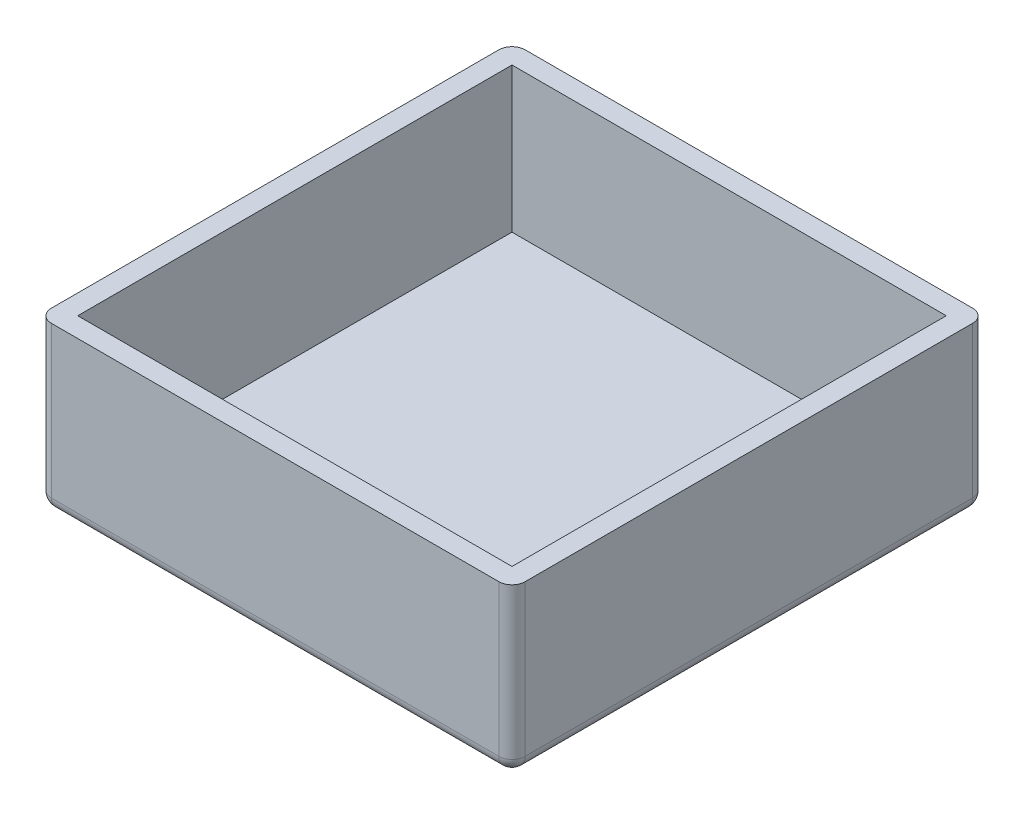
from build123d import *

# Parameters (mm, degrees)
SKETCH_1_W        = 66
SKETCH_1_H        = 66
EXTRUDE_1_DEPTH   = 3
SKETCH_1_2_W      = 72
SKETCH_1_2_H      = 72
SKETCH_1_2_W_2    = 66
SKETCH_1_2_H_2    = 66
EXTRUDE_1_2_DEPTH = 25
FILLET_1_R        = 2


with BuildPart() as part:
    # 草图1 → Extrude 1 (new body)
    with BuildSketch(Plane(origin=(0, 0, 0), x_dir=(1, 0, 0), z_dir=(0, 1, 0))):
        Rectangle(SKETCH_1_W, SKETCH_1_H)
    extrude(amount=EXTRUDE_1_DEPTH)

    # 草图1<2> → Extrude 1 2 (add)
    with BuildSketch(Plane(origin=(0, 0, 0), x_dir=(1, 0, 0), z_dir=(0, 1, 0))):
        Rectangle(SKETCH_1_2_W, SKETCH_1_2_H)
        Rectangle(SKETCH_1_2_W_2, SKETCH_1_2_H_2, mode=Mode.SUBTRACT)
    extrude(amount=EXTRUDE_1_2_DEPTH)

    # 圆角1
    fillet_1_edges = [part.edges().sort_by_distance(p)[0] for p in [
        (36, 0, 0),
        (0, 0, 36),
        (-36, 0, 0),
        (0, 0, -36),
        (-36, 12.5, -36),
        (36, 12.5, -36),
        (36, 12.5, 36),
        (-36, 12.5, 36),
    ]]
    fillet(fillet_1_edges, radius=FILLET_1_R)


solid = part.part
